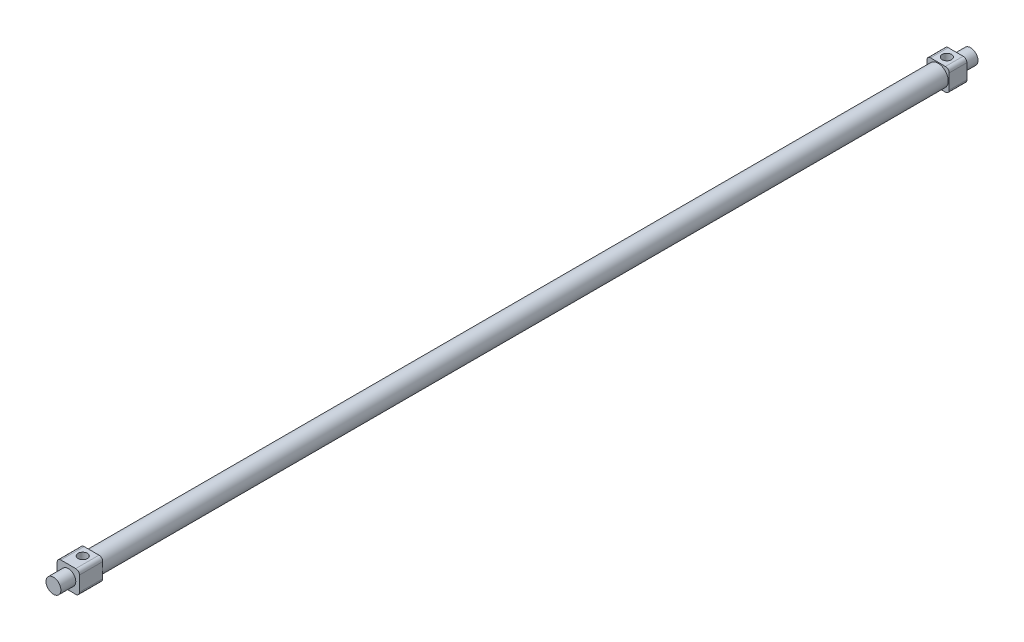
from build123d import *

# Parameters (mm, degrees)
SKETCH_1_W          = 12
SKETCH_1_H          = 12
EXTRUDE_1_DEPTH     = 9.5
SKETCH_2_R          = 5.5
EXTRUDE_2_DEPTH     = 455
SKETCH_3_W          = 12
SKETCH_3_H          = 12
EXTRUDE_3_DEPTH     = 12.5
SKETCH_4_R          = 4
EXTRUDE_4_DEPTH     = 8
CUT_EXTRUDE_START   = -6
SKETCH_6_R          = 2.5
CUT_EXTRUDE_2_DEPTH = 6
FILLET_1_R          = 2
SKETCH_7_R          = 4
EXTRUDE_5_DEPTH     = 8


with BuildPart() as part:
    # 草图1 → 凸台-拉伸1 (new body)
    with BuildSketch(Plane.XY):
        Rectangle(SKETCH_1_W, SKETCH_1_H)
    extrude(amount=EXTRUDE_1_DEPTH)

    # 草图2 → 凸台-拉伸2 (add)
    with BuildSketch(Plane.XY.offset(9.5)):
        Circle(SKETCH_2_R)
    extrude(amount=EXTRUDE_2_DEPTH)

    # 草图3 → 凸台-拉伸3 (add)
    with BuildSketch(Plane.XY.offset(464.5)):
        Rectangle(SKETCH_3_W, SKETCH_3_H)
    extrude(amount=EXTRUDE_3_DEPTH)

    # 草图4 → 凸台-拉伸4 (add)
    with BuildSketch(Plane.XY.offset(477)):
        Circle(SKETCH_4_R)
    extrude(amount=EXTRUDE_4_DEPTH)

    # 草图6 → 切除-拉伸2 (cut)
    with BuildSketch(Plane(origin=(0, 6, 0), x_dir=(1, 0, 0), z_dir=(0, 1, 0)).offset(CUT_EXTRUDE_START)):
        with Locations((0, -4.75)):
            Circle(SKETCH_6_R)
        with Locations((0, -469.25)):
            Circle(SKETCH_6_R)
    extrude(amount=CUT_EXTRUDE_2_DEPTH, mode=Mode.SUBTRACT)

    # 圆角1
    fillet_1_edges = [part.edges().sort_by_distance(p)[0] for p in [
        (6, -6, 470.75),
        (6, 6, 470.75),
        (-6, 6, 470.75),
        (-6, -6, 470.75),
        (6, -6, 4.75),
        (-6, -6, 4.75),
        (-6, 6, 4.75),
        (6, 6, 4.75),
    ]]
    fillet(fillet_1_edges, radius=FILLET_1_R)

    # 草图7 → 凸台-拉伸5 (add)
    with BuildSketch(Plane(origin=(0, 0, 0), x_dir=(-1, 0, 0), z_dir=(0, 0, -1))):
        Circle(SKETCH_7_R)
    extrude(amount=EXTRUDE_5_DEPTH)


solid = part.part
